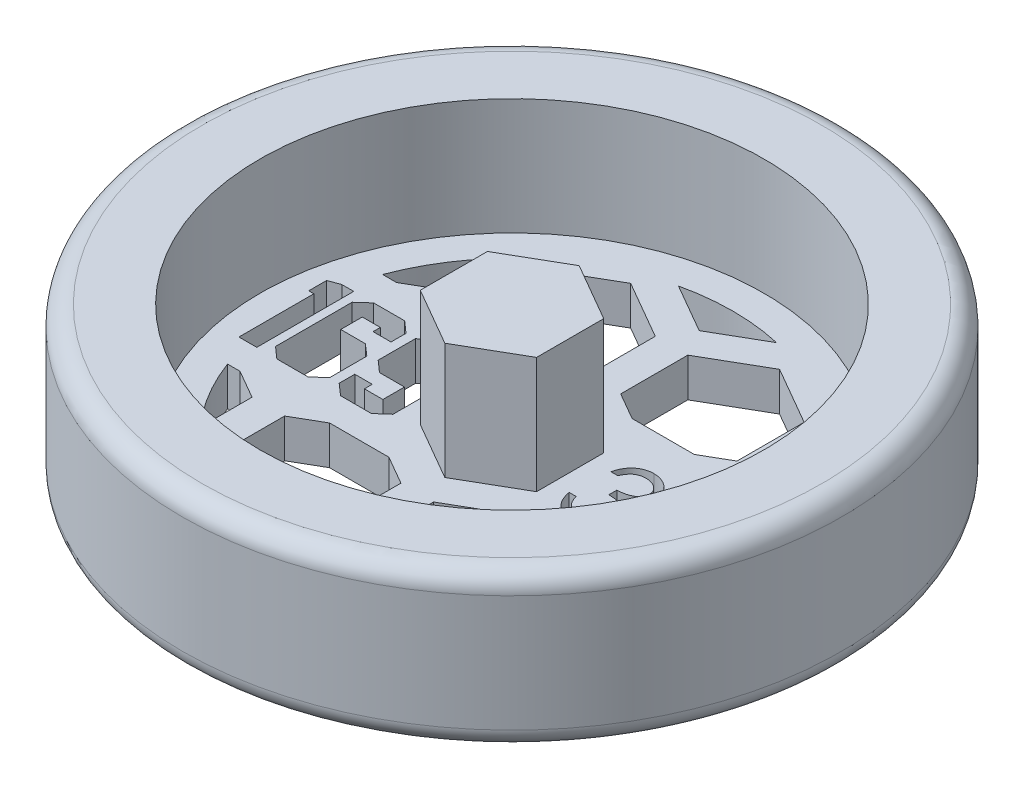
from build123d import *

# Parameters (mm, degrees)
BOSS_EXTRUDE1_DEPTH     = 9.525
CUT_EXTRUDE1_DEPTH      = 10.525
CUT_EXTRUDE1_DEPTH_BACK = 4.175
CUT_EXTRUDE2_DEPTH      = 10.525
CUT_EXTRUDE2_DEPTH_BACK = 4.1750001


with BuildPart() as part:
    # Sketch1 → Revolve1 (revolve)
    with BuildSketch(Plane.XY):
        with BuildLine():
            Line((0, 0), (25.4, 0))
            ThreePointArc((25.4, 0), (26.522532015, 0.464967985), (26.9875, 1.5875))
            Line((26.9875, 1.5875), (26.9875, 11.1125))
            ThreePointArc((26.9875, 11.1125), (26.522532015, 12.235032015), (25.4, 12.7))
            Line((25.4, 12.7), (20.6375, 12.7))
            Line((20.6375, 12.7), (20.6375, 3.175))
            Line((20.6375, 3.175), (0, 3.175))
            Line((0, 3.175), (0, 0))
        make_face()
    revolve(axis=Axis((0, 3.175, 0), (0, -1, 0)))

    # Sketch2 → Boss-Extrude1 (add)
    with BuildSketch(Plane(origin=(0, 3.175, 0), x_dir=(1, 0, 0), z_dir=(0, 1, 0))):
        Polygon((0, 5.499261314), (-4.7625, 2.749630657), (-4.7625, -2.749630657), (0, -5.499261314), (4.7625, -2.749630657), (4.7625, 2.749630657), align=None)
    extrude(amount=BOSS_EXTRUDE1_DEPTH)

    # Sketch3 → Cut-Extrude1 (cut, two sides)
    with BuildSketch(Plane(origin=(0, 3.175, 0), x_dir=(1, 0, 0), z_dir=(0, 1, 0))) as cut_extrude1_sk:
        Polygon((-6.60689834, -3.139369578), (-7.545565353, -3.96875), (-10.072630611, -3.96875), (-11.0127947, -3.139369578), (-11.0127947, -1.862363259), (-9.583086571, -1.862363259), (-9.583086571, -2.503112033), (-8.07103923, -2.503112033), (-8.07103923, -0.735064598), (-10.117542908, -0.735064598), (-11.053215768, 0.094315824), (-11.053215768, 3.134878348), (-10.117542908, 3.96875), (-7.556044889, 3.96875), (-6.60689834, 3.130387118), align=None)
        Polygon((-11.800256978, -3.139369578), (-12.740421068, -3.96875), (-15.286948321, -3.96875), (-16.22711241, -3.139369578), (-16.22711241, 3.134878348), (-15.297427857, 3.96875), (-12.755391833, 3.96875), (-11.815227744, 3.134878348), (-11.815227744, 1.907275556), (-13.285356941, 1.907275556), (-13.285356941, 2.503112033), (-14.761474444, 2.503112033), (-14.761474444, 0.735064598), (-12.740421068, 0.735064598), (-11.800256978, -0.088327518), align=None)
        Polygon((-16.929241324, -3.96875), (-18.394879291, -3.96875), (-18.394879291, 2.164772727), (-18.814060732, 2.164772727), (-18.814060732, 3.630410694), (-17.909826481, 3.96875), (-16.929241324, 3.96875), align=None)
        with BuildLine():
            Line((6.960576923, 1.709615385), (6.390705128, 1.709615385))
            add(Edge.make_bspline(
                [(6.390705128, 1.709615385), (6.406143884, 1.773537177), (6.43632539, 1.898499053), (6.499276702, 2.07703794), (6.567855351, 2.245990615), (6.650204155, 2.402193491), (6.74002718, 2.548785786), (6.842938404, 2.682442626), (6.9541899, 2.806563292), (7.077243737, 2.916714452), (7.206291451, 3.016459761), (7.343151404, 3.101504507), (7.485070083, 3.174664042), (7.633030767, 3.234935034), (7.787473964, 3.280338484), (7.947003424, 3.313280117), (8.112037202, 3.334672567), (8.224064974, 3.33676038), (8.280949519, 3.337820513)],
                knots=[0, 0, 0, 0, 0.000197149, 0.00038541, 0.000567311, 0.000743684, 0.000914521, 0.001082435, 0.001249032, 0.001413833, 0.00157717, 0.001737759, 0.001896483, 0.002055691, 0.002216275, 0.002378683, 0.002544033, 0.002714604, 0.002714604, 0.002714604, 0.002714604], degree=3))
            add(Edge.make_bspline(
                [(8.280949519, 3.337820513), (8.363831066, 3.335318195), (8.527786271, 3.330368142), (8.768656371, 3.285166236), (9.0009336, 3.213637782), (9.222075521, 3.114806877), (9.427486105, 2.992909894), (9.61025033, 2.847831015), (9.767890914, 2.682369425), (9.900142142, 2.499611772), (10.003692497, 2.30429392), (10.080049203, 2.103270777), (10.126534253, 1.897019201), (10.132558692, 1.757759566), (10.135576923, 1.687990785)],
                knots=[0, 0, 0, 0, 0.000248441, 0.000491463, 0.000732469, 0.000976186, 0.001216372, 0.001447214, 0.001673943, 0.001899893, 0.002121826, 0.002335172, 0.00254351, 0.002752682, 0.002752682, 0.002752682, 0.002752682], degree=3))
            add(Edge.make_bspline(
                [(10.135576923, 1.687990785), (10.133465836, 1.620849886), (10.129334768, 1.489465566), (10.094257902, 1.297656564), (10.035227825, 1.116878232), (9.953458398, 0.946369552), (9.847610157, 0.787211629), (9.719389693, 0.639046369), (9.567892007, 0.501216611), (9.453085933, 0.422259853), (9.393980369, 0.381610577)],
                knots=[0, 0, 0, 0, 0.000201307, 0.000393927, 0.000582588, 0.000770337, 0.000959438, 0.001154255, 0.001356876, 0.001571884, 0.001571884, 0.001571884, 0.001571884], degree=3))
            add(Edge.make_bspline(
                [(9.393980369, 0.381610577), (9.461529409, 0.348993037), (9.595363595, 0.284368257), (9.777790984, 0.157629954), (9.94339513, 0.011296295), (10.03574902, -0.102899661), (10.082151442, -0.160276442)],
                knots=[0, 0, 0, 0, 0.000224722, 0.00044524, 0.000664122, 0.000885153, 0.000885153, 0.000885153, 0.000885153], degree=3))
            add(Edge.make_bspline(
                [(10.082151442, -0.160276442), (10.112706449, -0.202109792), (10.173316103, -0.28509144), (10.248129143, -0.418507527), (10.315999965, -0.553402372), (10.368886791, -0.69339158), (10.409842236, -0.836852619), (10.439117608, -0.984031824), (10.457304264, -1.135049379), (10.459908765, -1.237216307), (10.461217949, -1.288571715)],
                knots=[0, 0, 0, 0, 0.000155272, 0.000308001, 0.000458187, 0.000607963, 0.000756132, 0.000905313, 0.00105773, 0.001211777, 0.001211777, 0.001211777, 0.001211777], degree=3))
            add(Edge.make_bspline(
                [(10.461217949, -1.288571715), (10.457962188, -1.377489352), (10.45146599, -1.554906178), (10.393401455, -1.817024601), (10.303388861, -2.073248013), (10.175559849, -2.318312364), (10.019771654, -2.547602484), (9.83442908, -2.752755216), (9.621638025, -2.929101255), (9.384319205, -3.076439812), (9.127203843, -3.194219471), (8.852202412, -3.275966546), (8.563277314, -3.329208573), (8.365144074, -3.334917893), (8.264413061, -3.337820513)],
                knots=[0, 0, 0, 0, 0.000266451, 0.000531648, 0.000801611, 0.001079241, 0.001358327, 0.001631199, 0.001905794, 0.002184633, 0.002466979, 0.002751475, 0.003043423, 0.003345349, 0.003345349, 0.003345349, 0.003345349], degree=3))
            add(Edge.make_bspline(
                [(8.264413061, -3.337820513), (8.196523759, -3.336245326), (8.062940251, -3.333145883), (7.866555618, -3.311957564), (7.679100535, -3.27325884), (7.500321551, -3.221182843), (7.330059842, -3.155157826), (7.168834965, -3.072936759), (7.015655015, -2.976214463), (6.87196549, -2.863849239), (6.737783517, -2.738153094), (6.616675003, -2.596894604), (6.506620807, -2.442685029), (6.410567734, -2.273733198), (6.324140692, -2.092222517), (6.253055242, -1.895828813), (6.190488567, -1.686307802), (6.161399282, -1.540298187), (6.146474359, -1.465384615)],
                knots=[0, 0, 0, 0, 0.000203669, 0.000400752, 0.000591596, 0.00077716, 0.000958812, 0.001138579, 0.001319262, 0.001501447, 0.001685017, 0.001869901, 0.002058732, 0.002252483, 0.002452209, 0.00266109, 0.002878455, 0.003107492, 0.003107492, 0.003107492, 0.003107492], degree=3))
            Line((6.146474359, -1.465384615), (6.716346154, -1.465384615))
            add(Edge.make_bspline(
                [(6.716346154, -1.465384615), (6.731192983, -1.514277825), (6.760071354, -1.609379365), (6.809228152, -1.746249634), (6.865232017, -1.871722102), (6.925311288, -1.986717195), (6.988409325, -2.092367411), (7.059012118, -2.185879087), (7.131890424, -2.271359526), (7.186825823, -2.319519036), (7.213711939, -2.343088942)],
                knots=[0, 0, 0, 0, 0.000153284, 0.000298151, 0.00043596, 0.000565114, 0.000687282, 0.000804565, 0.000916331, 0.001023461, 0.001023461, 0.001023461, 0.001023461], degree=3))
            add(Edge.make_bspline(
                [(7.213711939, -2.343088942), (7.249265728, -2.370499777), (7.320263559, -2.425236834), (7.43595735, -2.495089789), (7.557632215, -2.555616221), (7.687924552, -2.601850926), (7.824022779, -2.640998967), (7.968126713, -2.666617624), (8.118965007, -2.684194734), (8.221957949, -2.685745824), (8.274589343, -2.686538462)],
                knots=[0, 0, 0, 0, 0.000134583, 0.000268752, 0.000404717, 0.000541542, 0.000682898, 0.000829099, 0.000980107, 0.001137922, 0.001137922, 0.001137922, 0.001137922], degree=3))
            add(Edge.make_bspline(
                [(8.274589343, -2.686538462), (8.334013555, -2.685421033), (8.450212471, -2.683235999), (8.619766288, -2.663141503), (8.7810698, -2.633876324), (8.932332108, -2.588677055), (9.0755346, -2.532831796), (9.208669878, -2.462712546), (9.333485671, -2.380444265), (9.448383307, -2.286937506), (9.551698727, -2.184572794), (9.64266613, -2.077506222), (9.719999444, -1.966189217), (9.782381079, -1.850005769), (9.831639935, -1.729436997), (9.865173741, -1.604144549), (9.888490062, -1.475153795), (9.890388915, -1.387471237), (9.891346154, -1.343269231)],
                knots=[0, 0, 0, 0, 0.000178198, 0.000348452, 0.00051161, 0.000669393, 0.000821278, 0.000972056, 0.00111988, 0.001269077, 0.001415693, 0.001555599, 0.001690033, 0.001821502, 0.001950474, 0.002079778, 0.002210061, 0.002342506, 0.002342506, 0.002342506, 0.002342506], degree=3))
            add(Edge.make_bspline(
                [(9.891346154, -1.343269231), (9.88856975, -1.284102945), (9.883030756, -1.166064775), (9.840742334, -0.992405748), (9.77118468, -0.825086128), (9.673807409, -0.666960623), (9.55526973, -0.520410059), (9.416721971, -0.389651798), (9.257013614, -0.281756061), (9.110020423, -0.207209499), (8.979817924, -0.156342234), (8.86839287, -0.122460513), (8.743648746, -0.093770023), (8.607094085, -0.067077759), (8.457699964, -0.044360456), (8.295629026, -0.025416019), (8.12084843, -0.010257587), (7.999851601, -0.003488315), (7.9375, 0)],
                knots=[0, 0, 0, 0, 0.000177366, 0.000353849, 0.000532912, 0.000718999, 0.000908921, 0.001097014, 0.001288247, 0.00148508, 0.001590198, 0.001707288, 0.001834096, 0.001974049, 0.002124628, 0.0022873, 0.002463503, 0.002650842, 0.002650842, 0.002650842, 0.002650842], degree=3))
            Line((7.9375, 0), (7.9375, 0.651282051))
            add(Edge.make_bspline(
                [(7.9375, 0.651282051), (8.016060686, 0.652615195), (8.169941772, 0.655226497), (8.394721439, 0.686809601), (8.609665877, 0.730498741), (8.810011538, 0.797419018), (8.99261706, 0.875143557), (9.151039767, 0.965589708), (9.283060163, 1.066127896), (9.388036678, 1.178309916), (9.467011136, 1.298624359), (9.52475404, 1.424021724), (9.558863203, 1.555601092), (9.563416456, 1.645398561), (9.565705128, 1.690534856)],
                knots=[0, 0, 0, 0, 0.000235495, 0.000461277, 0.00067983, 0.000892625, 0.001093727, 0.001274383, 0.001438496, 0.001589702, 0.00173294, 0.001868428, 0.002002325, 0.002137646, 0.002137646, 0.002137646, 0.002137646], degree=3))
            add(Edge.make_bspline(
                [(9.565705128, 1.690534856), (9.564953268, 1.723695908), (9.563457479, 1.789668248), (9.544593846, 1.886052301), (9.516247372, 1.979489731), (9.477277006, 2.069583187), (9.425115931, 2.155707827), (9.362693641, 2.238597913), (9.288365802, 2.317780198), (9.203193348, 2.39158592), (9.111731931, 2.461924393), (9.011493053, 2.521639135), (8.90549908, 2.572702319), (8.793632664, 2.614810987), (8.675530773, 2.646487124), (8.551748304, 2.669230722), (8.422049221, 2.683450467), (8.333563365, 2.685497736), (8.288581731, 2.686538462)],
                knots=[0, 0, 0, 0, 9.9349e-05, 0.00019765, 0.000293417, 0.000391965, 0.000491224, 0.000594768, 0.000702764, 0.000816325, 0.000932589, 0.001048428, 0.001165628, 0.001285179, 0.00140645, 0.001531944, 0.001662444, 0.001797376, 0.001797376, 0.001797376, 0.001797376], degree=3))
            add(Edge.make_bspline(
                [(8.288581731, 2.686538462), (8.216279419, 2.684014133), (8.075056187, 2.679083533), (7.871466267, 2.635898066), (7.682201189, 2.566994972), (7.537532466, 2.484747922), (7.430702653, 2.403557849), (7.354363065, 2.332651234), (7.279395853, 2.253851682), (7.210732982, 2.162305773), (7.141293053, 2.064213168), (7.078075063, 1.954587346), (7.016643907, 1.836287945), (6.979627852, 1.752657293), (6.960576923, 1.709615385)],
                knots=[0, 0, 0, 0, 0.000216698, 0.000423262, 0.000621275, 0.000818969, 0.000919717, 0.001023253, 0.001131249, 0.001245492, 0.001366168, 0.00149161, 0.001624737, 0.00176591, 0.00176591, 0.00176591, 0.00176591], degree=3))
        make_face()
        Polygon((14.368910256, 3.337820513), (11.712900641, -4.070512821), (11.1125, -4.070512821), (13.768509615, 3.337820513), align=None)
        with BuildLine():
            add(Edge.make_bspline(
                [(17.944601362, 0.362530048), (17.996578012, 0.335428328), (18.097949838, 0.282570923), (18.24232563, 0.197461278), (18.374269561, 0.107761242), (18.497442437, 0.017707611), (18.609680231, -0.076148385), (18.709727951, -0.174179968), (18.800056919, -0.273940183), (18.878845512, -0.377118322), (18.948145488, -0.483440271), (19.008038933, -0.593185095), (19.059233001, -0.706112286), (19.099805761, -0.823454535), (19.133228155, -0.943488152), (19.156225324, -1.067763062), (19.16859316, -1.195460366), (19.170931436, -1.281762857), (19.172115385, -1.325460737)],
                knots=[0, 0, 0, 0, 0.00017584, 0.000342947, 0.000502414, 0.000654298, 0.000800555, 0.000940883, 0.001074198, 0.001203952, 0.001329909, 0.001454575, 0.001578694, 0.001701398, 0.001826685, 0.001952179, 0.002080017, 0.002211136, 0.002211136, 0.002211136, 0.002211136], degree=3))
            add(Edge.make_bspline(
                [(19.172115385, -1.325460737), (19.170715807, -1.386598052), (19.167945519, -1.507611738), (19.143815548, -1.686221112), (19.107687715, -1.859688202), (19.054929172, -2.027974978), (18.986506305, -2.190152841), (18.902184046, -2.346360616), (18.806732288, -2.499158505), (18.730074654, -2.593173705), (18.691286058, -2.640745192)],
                knots=[0, 0, 0, 0, 0.000183332, 0.000362883, 0.000539769, 0.000714376, 0.000891093, 0.001066933, 0.001246543, 0.001430513, 0.001430513, 0.001430513, 0.001430513], degree=3))
            add(Edge.make_bspline(
                [(18.691286058, -2.640745192), (18.64078274, -2.69625104), (18.540400188, -2.806576834), (18.368436877, -2.94981616), (18.179711459, -3.070192918), (17.974954198, -3.168294784), (17.754712429, -3.244650557), (17.519033077, -3.299519125), (17.267456686, -3.330946961), (17.094545331, -3.335489913), (17.005839343, -3.337820513)],
                knots=[0, 0, 0, 0, 0.000224931, 0.000447082, 0.000669033, 0.000894901, 0.001126621, 0.001366982, 0.001619583, 0.001885684, 0.001885684, 0.001885684, 0.001885684], degree=3))
            add(Edge.make_bspline(
                [(17.005839343, -3.337820513), (16.920543624, -3.335729589), (16.754566817, -3.331660862), (16.512980382, -3.304093822), (16.28778567, -3.255783264), (16.077673299, -3.18966233), (15.883909955, -3.10364663), (15.707047758, -2.996588517), (15.544534979, -2.872797186), (15.40130352, -2.728717359), (15.274143058, -2.574398076), (15.162441019, -2.415191584), (15.069596619, -2.25108335), (14.990988889, -2.084520369), (14.930812619, -1.913168061), (14.889134466, -1.737908037), (14.862665282, -1.559046421), (14.859143509, -1.438338993), (14.857371795, -1.377614183)],
                knots=[0, 0, 0, 0, 0.000255882, 0.000497919, 0.0007282, 0.000945837, 0.001157653, 0.001362498, 0.001564768, 0.001768948, 0.001970416, 0.002164142, 0.00235158, 0.002535397, 0.002716031, 0.002895284, 0.003075177, 0.003257296, 0.003257296, 0.003257296, 0.003257296], degree=3))
            add(Edge.make_bspline(
                [(14.857371795, -1.377614183), (14.858420236, -1.333056791), (14.860492326, -1.244995659), (14.874833979, -1.114894449), (14.897890759, -0.988264319), (14.929204345, -0.864637541), (14.97164235, -0.744914147), (15.022881649, -0.628526859), (15.08262962, -0.515344279), (15.151719734, -0.404747452), (15.232096263, -0.298286052), (15.323107456, -0.194153319), (15.426572304, -0.093965074), (15.54133977, 0.003502754), (15.666098292, 0.099979164), (15.804088383, 0.190250271), (15.951651983, 0.280706865), (16.056527505, 0.334787684), (16.110326522, 0.362530048)],
                knots=[0, 0, 0, 0, 0.000133661, 0.00026416, 0.000392157, 0.000519576, 0.000646302, 0.000772746, 0.000900774, 0.001029947, 0.00116351, 0.001300524, 0.00144445, 0.001595115, 0.001752092, 0.001917202, 0.002089542, 0.002271069, 0.002271069, 0.002271069, 0.002271069], degree=3))
            add(Edge.make_bspline(
                [(16.110326522, 0.362530048), (16.036682171, 0.402688843), (15.894086094, 0.480447509), (15.705274394, 0.623316714), (15.543094263, 0.778053179), (15.412003561, 0.947924378), (15.30882109, 1.127623707), (15.238030193, 1.31602685), (15.190139429, 1.509640371), (15.185395386, 1.641913042), (15.183012821, 1.708343349)],
                knots=[0, 0, 0, 0, 0.000251342, 0.000486669, 0.000707966, 0.000921948, 0.001128163, 0.001327073, 0.001524242, 0.001723173, 0.001723173, 0.001723173, 0.001723173], degree=3))
            add(Edge.make_bspline(
                [(15.183012821, 1.708343349), (15.185979947, 1.776011777), (15.191944389, 1.912037117), (15.240174128, 2.114522512), (15.318769106, 2.31339828), (15.425668629, 2.507700502), (15.558814007, 2.690853034), (15.718555597, 2.855120179), (15.901078721, 2.999013869), (16.10547228, 3.119802068), (16.32542945, 3.218106706), (16.557505121, 3.285921845), (16.797655758, 3.330255942), (16.961118764, 3.335275444), (17.044000401, 3.337820513)],
                knots=[0, 0, 0, 0, 0.000202829, 0.000407721, 0.00062079, 0.000842814, 0.001071289, 0.001297982, 0.001528034, 0.001766476, 0.002008514, 0.00224878, 0.002490326, 0.002738767, 0.002738767, 0.002738767, 0.002738767], degree=3))
            add(Edge.make_bspline(
                [(17.044000401, 3.337820513), (17.124743036, 3.335196433), (17.283958316, 3.330022047), (17.517991426, 3.286865854), (17.741919418, 3.214785154), (17.95497008, 3.117000192), (18.153329325, 2.996555313), (18.328593515, 2.850685156), (18.483411199, 2.687142628), (18.611471457, 2.504045634), (18.716995557, 2.310490025), (18.790475763, 2.10797488), (18.837560059, 1.900875873), (18.843498877, 1.760744066), (18.846474359, 1.690534856)],
                knots=[0, 0, 0, 0, 0.000242091, 0.000477377, 0.000711103, 0.000946181, 0.001179183, 0.001405083, 0.001628266, 0.001852736, 0.002073547, 0.002287642, 0.002497223, 0.002707663, 0.002707663, 0.002707663, 0.002707663], degree=3))
            add(Edge.make_bspline(
                [(18.846474359, 1.690534856), (18.843871656, 1.621634337), (18.838760096, 1.486317634), (18.795761634, 1.289056662), (18.723347479, 1.104322391), (18.624479498, 0.930018606), (18.495618971, 0.769306461), (18.338485983, 0.620142294), (18.154333301, 0.481300762), (18.015974265, 0.402948359), (17.944601362, 0.362530048)],
                knots=[0, 0, 0, 0, 0.000206544, 0.000405641, 0.000602178, 0.000799872, 0.001004492, 0.001217712, 0.00144846, 0.001694318, 0.001694318, 0.001694318, 0.001694318], degree=3))
        make_face()
    extrude(amount=CUT_EXTRUDE1_DEPTH, mode=Mode.SUBTRACT)
    extrude(cut_extrude1_sk.sketch, amount=-CUT_EXTRUDE1_DEPTH_BACK, mode=Mode.SUBTRACT)

    # Sketch4 → Cut-Extrude2 (cut, two sides)
    with BuildSketch(Plane(origin=(0, 3.175, 0), x_dir=(1, 0, 0), z_dir=(0, 1, 0))) as cut_extrude2_sk:
        with BuildLine():
            Line((-16.946887804, 6.35), (-15.805631592, 6.35))
            Line((-15.805631592, 6.35), (-13.589, 7.629772846))
            Line((-13.589, 7.629772846), (-13.589, 11.952346433))
            ThreePointArc((-13.589, 11.952346433), (-15.522779467, 9.303914438), (-16.946887804, 6.35))
        make_face()
        Polygon((-8.705368408, 6.35), (-3.613631592, 6.35), (-1.397, 7.629772846), (-1.397, 13.12903416), (-6.1595, 15.878664817), (-10.922, 13.12903416), (-10.922, 7.629772846), align=None)
        with BuildLine():
            ThreePointArc((4.014638475, 17.64659129), (0, 18.0975), (-4.014638475, 17.64659129))
            Line((-4.014638475, 17.64659129), (0, 15.328738686))
            Line((0, 15.328738686), (4.014638475, 17.64659129))
        make_face()
        Polygon((1.27, 7.629772846), (3.486631592, 6.35), (8.578368408, 6.35), (10.795, 7.629772846), (10.795, 13.12903416), (6.0325, 15.878664817), (1.27, 13.12903416), align=None)
        with BuildLine():
            Line((13.462, 7.629772846), (15.678631592, 6.35))
            Line((15.678631592, 6.35), (16.946887804, 6.35))
            ThreePointArc((16.946887804, 6.35), (15.473427829, 9.385762487), (13.462, 12.095208235))
            Line((13.462, 12.095208235), (13.462, 7.629772846))
        make_face()
        Polygon((8.458522628, -6.35), (3.606477372, -6.35), (1.27, -7.69896584), (1.27, -13.198227154), (6.0325, -15.947857811), (10.795, -13.198227154), (10.795, -7.69896584), align=None)
        with BuildLine():
            Line((16.946887804, -6.35), (15.798477372, -6.35))
            Line((15.798477372, -6.35), (13.462, -7.69896584))
            Line((13.462, -7.69896584), (13.462, -12.095208235))
            ThreePointArc((13.462, -12.095208235), (15.473427829, -9.385762487), (16.946887804, -6.35))
        make_face()
        with BuildLine():
            Line((0, -15.328738686), (-4.014638475, -17.64659129))
            ThreePointArc((-4.014638475, -17.64659129), (0, -18.0975), (4.014638475, -17.64659129))
            Line((4.014638475, -17.64659129), (0, -15.328738686))
        make_face()
        Polygon((-1.397, -7.69896584), (-3.733477372, -6.35), (-8.585522628, -6.35), (-10.922, -7.69896584), (-10.922, -13.198227154), (-6.1595, -15.947857811), (-1.397, -13.198227154), align=None)
        with BuildLine():
            Line((-13.589, -7.69896584), (-15.925477372, -6.35))
            Line((-15.925477372, -6.35), (-16.946887804, -6.35))
            ThreePointArc((-16.946887804, -6.35), (-15.522779467, -9.303914438), (-13.589, -11.952346433))
            Line((-13.589, -11.952346433), (-13.589, -7.69896584))
        make_face()
    extrude(amount=CUT_EXTRUDE2_DEPTH, mode=Mode.SUBTRACT)
    extrude(cut_extrude2_sk.sketch, amount=-CUT_EXTRUDE2_DEPTH_BACK, mode=Mode.SUBTRACT)


solid = part.part
